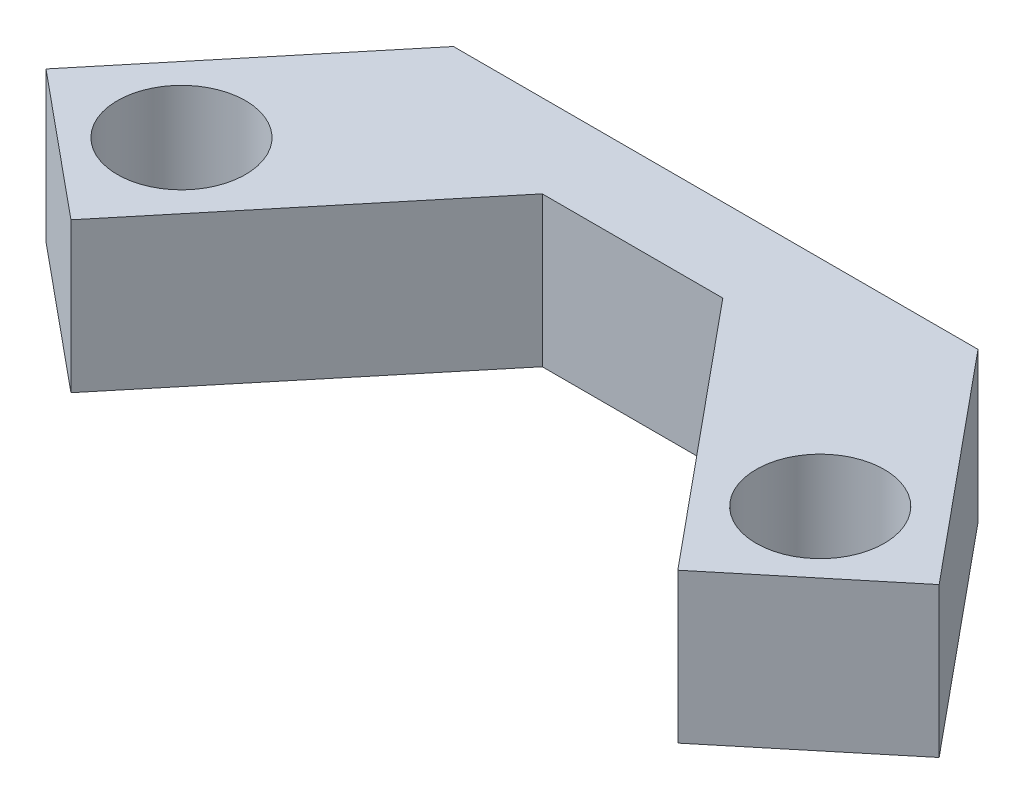
from build123d import *

# Parameters (mm, degrees)
SKETCH8_R           = 7.7
BOSS_EXTRUDE4_DEPTH = 18


with BuildPart() as part:
    # Sketch8 → Boss-Extrude4 (new body)
    with BuildSketch(Plane(origin=(0, 0, 0), x_dir=(1, 0, 0), z_dir=(0, 1, 0))):
        Polygon((-33.238261498, 15.229126464), (29.811738502, 15.229126464), (51.963681539, -11.5942691), (34.761968411, -25.80020244), (9.13658013, 5.229126464), (-12.563103125, 5.229126464), (-38.188491406, -25.80020244), (-55.390204534, -11.5942691), align=None)
        with Locations((36.676738502, -10.601172055)):
            Circle(SKETCH8_R, mode=Mode.SUBTRACT)
        with Locations((-40.103261498, -10.601172055)):
            Circle(SKETCH8_R, mode=Mode.SUBTRACT)
    extrude(amount=BOSS_EXTRUDE4_DEPTH)


solid = part.part
